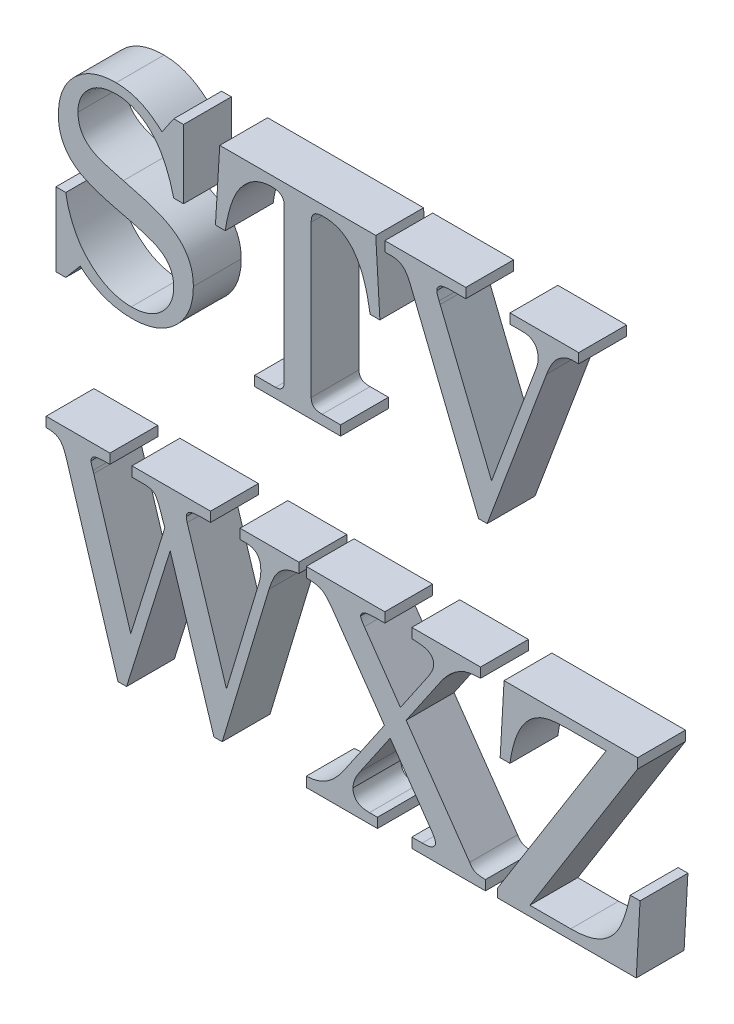
from build123d import *

# Parameters (mm, degrees)
BOSS_EXTRU_1_DEPTH   = 10
BOSS_EXTRU_1_2_DEPTH = 10
BOSS_EXTRU_1_3_DEPTH = 10
BOSS_EXTRU_1_4_DEPTH = 10
BOSS_EXTRU_1_5_DEPTH = 10
BOSS_EXTRU_1_6_DEPTH = 10


with BuildPart() as part:
    # Esquisse1 → Boss.-Extru.1 (new body)
    with BuildSketch(Plane.XY):
        with BuildLine():
            Line((25.240384615, 36.41025641), (27.692307692, 40))
            Line((27.692307692, 40), (29.743589744, 40))
            Line((29.743589744, 40), (29.743589744, 25.641025641))
            Line((29.743589744, 25.641025641), (27.692307692, 25.641025641))
            add(Edge.make_bspline(
                [(27.692307692, 25.641025641), (27.553181711, 26.179311808), (27.282139165, 27.227990507), (26.802654808, 28.731888364), (26.274272502, 30.123518089), (25.698788399, 31.40146317), (25.073905469, 32.567144603), (24.402423476, 33.624942096), (23.671265147, 34.562887028), (22.899710677, 35.395222104), (22.085774967, 36.11732818), (21.245314447, 36.749090998), (20.364784693, 37.267931511), (19.464598535, 37.707675003), (18.529639623, 38.045427942), (17.563164047, 38.285607061), (16.567118961, 38.434319164), (15.892603331, 38.452421333), (15.552884615, 38.461538462)],
                knots=[0, 0, 0, 0, 0.001667687, 0.003248956, 0.004732627, 0.006131202, 0.007450498, 0.008697438, 0.009885121, 0.011013336, 0.01209732, 0.013145408, 0.014162311, 0.015158611, 0.016147147, 0.017138278, 0.018142282, 0.019161045, 0.019161045, 0.019161045, 0.019161045], degree=3))
            add(Edge.make_bspline(
                [(15.552884615, 38.461538462), (15.272209756, 38.455302295), (14.719850589, 38.443029718), (13.911469306, 38.348994358), (13.142779475, 38.176929329), (12.412137501, 37.946451231), (11.719817849, 37.648188369), (11.064576365, 37.287268778), (10.455177464, 36.850531061), (9.888602709, 36.357009981), (9.380562766, 35.813737068), (8.927185364, 35.242214959), (8.539763693, 34.64394813), (8.234084963, 34.009426851), (7.992344887, 33.349151471), (7.816038992, 32.659722843), (7.70807936, 31.939857185), (7.69762473, 31.450699764), (7.692307692, 31.201923077)],
                knots=[0, 0, 0, 0, 0.000841956, 0.001656943, 0.002436538, 0.003201835, 0.003952008, 0.004694482, 0.005441524, 0.006196815, 0.00694506, 0.007669633, 0.008383134, 0.009078359, 0.009778002, 0.010489295, 0.011210004, 0.011955885, 0.011955885, 0.011955885, 0.011955885], degree=3))
            add(Edge.make_bspline(
                [(7.692307692, 31.201923077), (7.699248617, 30.893880321), (7.712750542, 30.29465611), (7.8845465, 29.426813587), (8.134269771, 28.612629636), (8.499872163, 27.859599457), (8.966724295, 27.171098619), (9.548415028, 26.556699063), (10.223004408, 26.003472237), (10.870971957, 25.596855719), (11.473790534, 25.304838429), (12.021905423, 25.072016406), (12.662222215, 24.835627315), (13.390172204, 24.585013966), (14.211354752, 24.343156674), (15.116187379, 24.072217211), (16.117575475, 23.81324236), (16.816095668, 23.639872024), (17.179487179, 23.549679487)],
                knots=[0, 0, 0, 0, 0.000922728, 0.001794948, 0.002643891, 0.003471736, 0.004296278, 0.00512965, 0.006000692, 0.006907806, 0.007416667, 0.00800902, 0.008693636, 0.009463951, 0.010318172, 0.011261441, 0.012297359, 0.013420641, 0.013420641, 0.013420641, 0.013420641], degree=3))
            add(Edge.make_bspline(
                [(17.179487179, 23.549679487), (17.692722554, 23.420396835), (18.680961183, 23.171462102), (20.105112481, 22.785378511), (21.41578255, 22.405792592), (22.61318463, 22.016892989), (23.699593848, 21.645045209), (24.673814989, 21.277244957), (25.533718177, 20.911471476), (26.511256747, 20.426104367), (27.595160321, 19.797243684), (28.722158388, 18.92220408), (29.680096621, 17.957028879), (30.458532703, 16.889605146), (31.056086728, 15.725167458), (31.496480116, 14.47373712), (31.742780636, 13.118573256), (31.777196472, 12.185790418), (31.794871795, 11.706730769)],
                knots=[0, 0, 0, 0, 0.001587772, 0.003057268, 0.004426499, 0.005680832, 0.006833815, 0.007871065, 0.00880431, 0.009635676, 0.011144556, 0.012555017, 0.013903554, 0.015211388, 0.016501551, 0.017816753, 0.019177753, 0.020614754, 0.020614754, 0.020614754, 0.020614754], degree=3))
            add(Edge.make_bspline(
                [(31.794871795, 11.706730769), (31.784598641, 11.276112882), (31.764417411, 10.430180018), (31.590533483, 9.190667589), (31.314921376, 8.004266225), (30.907158911, 6.880011916), (30.404749065, 5.803277343), (29.771791632, 4.793886611), (29.039992356, 3.830741723), (28.194344492, 2.941307065), (27.259659656, 2.134242835), (26.253213253, 1.425494413), (25.183772831, 0.820797931), (24.045313265, 0.328008179), (22.83772445, -0.04505345), (21.56731616, -0.318967924), (20.231163121, -0.479940307), (19.319345284, -0.501712882), (18.854166667, -0.512820513)],
                knots=[0, 0, 0, 0, 0.001291283, 0.002536677, 0.003747488, 0.00493868, 0.006117899, 0.007305312, 0.008505685, 0.009741323, 0.010979816, 0.012204729, 0.013428201, 0.014659206, 0.015918749, 0.017213755, 0.018553503, 0.019948861, 0.019948861, 0.019948861, 0.019948861], degree=3))
            add(Edge.make_bspline(
                [(18.854166667, -0.512820513), (18.348699871, -0.501037152), (17.352712679, -0.477818859), (15.883263236, -0.277315957), (14.465374422, 0.037644294), (13.098626932, 0.493907672), (11.781796541, 1.068874362), (10.518356381, 1.781907837), (9.299626653, 2.61450555), (8.546539029, 3.261838478), (8.165064103, 3.58974359)],
                knots=[0, 0, 0, 0, 0.001515779, 0.002986737, 0.004440772, 0.005867346, 0.007302514, 0.008744666, 0.010213812, 0.011721947, 0.011721947, 0.011721947, 0.011721947], degree=3))
            Line((8.165064103, 3.58974359), (5.128205128, 0))
            Line((5.128205128, 0), (3.076923077, 0))
            Line((3.076923077, 0), (3.076923077, 15.384615385))
            Line((3.076923077, 15.384615385), (5.128205128, 15.384615385))
            add(Edge.make_bspline(
                [(5.128205128, 15.384615385), (5.227295246, 14.862009498), (5.421431873, 13.838123903), (5.838745888, 12.360227949), (6.321047277, 10.957720396), (6.908874894, 9.644591262), (7.574068258, 8.413905481), (8.321983933, 7.265211629), (9.165094836, 6.208715581), (10.085892136, 5.239375239), (11.064054699, 4.373756667), (12.076720867, 3.612806258), (13.126060144, 2.973725784), (14.207153902, 2.456645172), (15.314350023, 2.036576413), (16.457884168, 1.753826597), (17.630125488, 1.567988769), (18.423434687, 1.548337408), (18.822115385, 1.538461538)],
                knots=[0, 0, 0, 0, 0.001595034, 0.00312498, 0.004602406, 0.006040813, 0.00743555, 0.008795678, 0.010147187, 0.011484776, 0.01280166, 0.01406128, 0.015280203, 0.01648079, 0.017652143, 0.01882596, 0.020009038, 0.021204265, 0.021204265, 0.021204265, 0.021204265], degree=3))
            add(Edge.make_bspline(
                [(18.822115385, 1.538461538), (19.140180676, 1.547428591), (19.764651593, 1.56503398), (20.680196455, 1.665651369), (21.551164166, 1.852853228), (22.377850006, 2.108275627), (23.162468253, 2.435154228), (23.891585787, 2.851804309), (24.588812069, 3.321558529), (25.221703547, 3.87438076), (25.797035009, 4.473290096), (26.306268941, 5.105907902), (26.732101466, 5.776896733), (27.088626844, 6.475411869), (27.36227179, 7.209466495), (27.553823886, 7.972710364), (27.668600027, 8.767889318), (27.684298307, 9.307844148), (27.692307692, 9.583333333)],
                knots=[0, 0, 0, 0, 0.000954367, 0.001873749, 0.00275854, 0.003622774, 0.004466596, 0.005302468, 0.006138148, 0.006984668, 0.007817731, 0.008627383, 0.009416473, 0.010197672, 0.010976071, 0.011761205, 0.012554433, 0.013380726, 0.013380726, 0.013380726, 0.013380726], degree=3))
            add(Edge.make_bspline(
                [(27.692307692, 9.583333333), (27.68194472, 9.891254008), (27.661685608, 10.49322411), (27.49074658, 11.368858625), (27.201004896, 12.184165029), (26.794266985, 12.941590037), (26.267227117, 13.638486949), (25.606548465, 14.273334742), (24.802340866, 14.828846703), (24.031904302, 15.248770641), (23.308867989, 15.57392759), (22.633586054, 15.827349554), (21.840217895, 16.087229272), (20.929938511, 16.369952622), (19.901494168, 16.664212569), (18.749234303, 16.967842177), (17.481080511, 17.288370641), (16.592228885, 17.496097613), (16.129807692, 17.604166667)],
                knots=[0, 0, 0, 0, 0.00092318, 0.001804772, 0.002663939, 0.003510004, 0.004373792, 0.005274833, 0.006246369, 0.007297057, 0.007903178, 0.008623441, 0.009459621, 0.010407507, 0.011482838, 0.012668438, 0.013982174, 0.01540679, 0.01540679, 0.01540679, 0.01540679], degree=3))
            add(Edge.make_bspline(
                [(16.129807692, 17.604166667), (15.618979592, 17.729742315), (14.63427351, 17.971810252), (13.219982688, 18.364599653), (11.922260737, 18.769265224), (10.744720407, 19.195056025), (9.68214472, 19.622654224), (8.744927093, 20.072956892), (7.916701023, 20.523762058), (7.427939651, 20.863893873), (7.195512821, 21.025641026)],
                knots=[0, 0, 0, 0, 0.001578037, 0.00304193, 0.004402812, 0.005654916, 0.006797692, 0.007837045, 0.008773311, 0.009622254, 0.009622254, 0.009622254, 0.009622254], degree=3))
            add(Edge.make_bspline(
                [(7.195512821, 21.025641026), (6.909215095, 21.256868185), (6.343332173, 21.713901159), (5.606504506, 22.503659275), (4.977502328, 23.362434111), (4.476885052, 24.299291492), (4.067445086, 25.298268336), (3.792418677, 26.37421358), (3.619471551, 27.518399719), (3.599822213, 28.305971302), (3.58974359, 28.709935897)],
                knots=[0, 0, 0, 0, 0.00110292, 0.002179982, 0.003229784, 0.004287506, 0.00535883, 0.006460818, 0.007611014, 0.008822249, 0.008822249, 0.008822249, 0.008822249], degree=3))
            add(Edge.make_bspline(
                [(3.58974359, 28.709935897), (3.601614972, 29.132352706), (3.624910044, 29.961256205), (3.775347577, 31.17519074), (4.041353115, 32.332450589), (4.417712401, 33.426838537), (4.895029112, 34.467617259), (5.480555315, 35.445776707), (6.176587276, 36.364330471), (6.966803201, 37.219551246), (7.843172501, 37.991386634), (8.784810291, 38.668669299), (9.78536255, 39.243050089), (10.84738629, 39.707079383), (11.969076894, 40.071377248), (13.151125384, 40.321120884), (14.388771201, 40.491169831), (15.234449304, 40.505515682), (15.665064103, 40.512820513)],
                knots=[0, 0, 0, 0, 0.001267268, 0.002486744, 0.003662692, 0.004823252, 0.005952605, 0.007091807, 0.008236042, 0.009404101, 0.010579257, 0.011733354, 0.01287829, 0.014033582, 0.015204277, 0.016409747, 0.017654084, 0.018945044, 0.018945044, 0.018945044, 0.018945044], degree=3))
            add(Edge.make_bspline(
                [(15.665064103, 40.512820513), (16.085049285, 40.502985724), (16.915473481, 40.483539688), (18.144832223, 40.299195909), (19.342159024, 40.003668978), (20.51945144, 39.582136122), (21.687366395, 39.016847232), (22.87081849, 38.308824432), (24.06451382, 37.427656182), (24.838930687, 36.757606762), (25.240384615, 36.41025641)],
                knots=[0, 0, 0, 0, 0.001259263, 0.002489902, 0.003720073, 0.004954385, 0.006233855, 0.007606669, 0.00908594, 0.010678215, 0.010678215, 0.010678215, 0.010678215], degree=3))
        make_face()
    extrude(amount=BOSS_EXTRU_1_DEPTH)


with BuildPart() as body_2:
    # Esquisse1 → Boss.-Extru.1 2 (new body)
    with BuildSketch(Plane.XY):
        with BuildLine():
            Line((37.307692308, 40), (69.903846154, 40))
            Line((69.903846154, 40), (70.769230769, 25.128205128))
            Line((70.769230769, 25.128205128), (68.717948718, 25.128205128))
            add(Edge.make_bspline(
                [(68.717948718, 25.128205128), (68.636550102, 25.64708069), (68.478670366, 26.653485231), (68.181635563, 28.108354031), (67.841608832, 29.463035931), (67.445099767, 30.715466879), (67.021305448, 31.875062607), (66.526317264, 32.925477474), (66.00398304, 33.885549653), (65.421452018, 34.736779972), (64.808044379, 35.501675558), (64.128262052, 36.149579207), (63.414298556, 36.712250919), (62.644110542, 37.162224119), (61.830767468, 37.520714641), (60.967278617, 37.764192916), (60.0620966, 37.925141897), (59.442490838, 37.940757023), (59.126602564, 37.948717949)],
                knots=[0, 0, 0, 0, 0.001575492, 0.003055806, 0.004453118, 0.005763331, 0.006995639, 0.00815354, 0.009243902, 0.010270669, 0.011244318, 0.012179349, 0.013081708, 0.013965337, 0.014848094, 0.015740724, 0.016650981, 0.017597716, 0.017597716, 0.017597716, 0.017597716], degree=3))
            add(Edge.make_bspline(
                [(59.126602564, 37.948717949), (58.88846848, 37.944303443), (58.44687272, 37.936117185), (57.84386134, 37.835634707), (57.35710928, 37.672425736), (56.975480164, 37.435827793), (56.71811376, 37.094671977), (56.531855697, 36.688271899), (56.432997427, 36.190320088), (56.418233977, 35.833718576), (56.41025641, 35.641025641)],
                knots=[0, 0, 0, 0, 0.000713861, 0.001323783, 0.001825593, 0.002247847, 0.002647043, 0.003088039, 0.003579964, 0.004158276, 0.004158276, 0.004158276, 0.004158276], degree=3))
            Line((56.41025641, 35.641025641), (56.41025641, 3.926282051))
            add(Edge.make_bspline(
                [(56.41025641, 3.926282051), (56.414572578, 3.775875613), (56.422711861, 3.492244282), (56.531881444, 3.097969622), (56.696129476, 2.761476266), (56.943092041, 2.489784073), (57.271798787, 2.284295305), (57.682959722, 2.146309791), (58.178303859, 2.069868353), (58.533363542, 2.057818405), (58.725961538, 2.051282051)],
                knots=[0, 0, 0, 0, 0.000449861, 0.000848333, 0.001217445, 0.001563484, 0.001934677, 0.002368037, 0.002855437, 0.00343325, 0.00343325, 0.00343325, 0.00343325], degree=3))
            Line((58.725961538, 2.051282051), (62.564102564, 2.051282051))
            Line((62.564102564, 2.051282051), (62.564102564, 0))
            Line((62.564102564, 0), (44.615384615, 0))
            Line((44.615384615, 0), (44.615384615, 2.051282051))
            Line((44.615384615, 2.051282051), (48.974358974, 2.051282051))
            add(Edge.make_bspline(
                [(48.974358974, 2.051282051), (49.11082903, 2.058461363), (49.370273561, 2.072110021), (49.737972734, 2.14608526), (50.050730768, 2.295773456), (50.313029207, 2.496832162), (50.510622604, 2.752282351), (50.673939749, 3.034115284), (50.747793654, 3.367283856), (50.761870758, 3.597554853), (50.769230769, 3.717948718)],
                knots=[0, 0, 0, 0, 0.000409909, 0.000779282, 0.001116201, 0.001441585, 0.001760693, 0.0020798, 0.002410177, 0.002772176, 0.002772176, 0.002772176, 0.002772176], degree=3))
            Line((50.769230769, 3.717948718), (50.769230769, 35.881410256))
            add(Edge.make_bspline(
                [(50.769230769, 35.881410256), (50.761513761, 36.042220834), (50.746894452, 36.346864766), (50.638159293, 36.778060346), (50.43094411, 37.138487561), (50.147185925, 37.440348655), (49.775428711, 37.674146957), (49.312640697, 37.843861647), (48.756015685, 37.93235937), (48.354983293, 37.94302673), (48.141025641, 37.948717949)],
                knots=[0, 0, 0, 0, 0.000482436, 0.000913939, 0.001319439, 0.001716215, 0.002145182, 0.002624412, 0.003185596, 0.003827422, 0.003827422, 0.003827422, 0.003827422], degree=3))
            add(Edge.make_bspline(
                [(48.141025641, 37.948717949), (47.81977755, 37.938245835), (47.186106912, 37.917589304), (46.256697078, 37.744137729), (45.370474947, 37.460347878), (44.517764545, 37.075997649), (43.717112964, 36.561983868), (42.946805191, 35.951954917), (42.233835267, 35.213323915), (41.800840602, 34.664697342), (41.578525641, 34.383012821)],
                knots=[0, 0, 0, 0, 0.000963173, 0.001899885, 0.002824837, 0.003749927, 0.004696967, 0.005671801, 0.00669173, 0.007767986, 0.007767986, 0.007767986, 0.007767986], degree=3))
            add(Edge.make_bspline(
                [(41.578525641, 34.383012821), (41.400397257, 34.124106189), (41.030416578, 33.586345453), (40.544210115, 32.689543917), (40.098284908, 31.686342522), (39.691349144, 30.577469885), (39.323739493, 29.36522144), (39.000110092, 28.047939745), (38.698940288, 26.627260349), (38.542460274, 25.639179569), (38.461538462, 25.128205128)],
                knots=[0, 0, 0, 0, 0.000942282, 0.001957162, 0.003054684, 0.00423355, 0.005498383, 0.006852929, 0.008301854, 0.009853634, 0.009853634, 0.009853634, 0.009853634], degree=3))
            Line((38.461538462, 25.128205128), (36.41025641, 25.128205128))
            Line((36.41025641, 25.128205128), (37.307692308, 40))
        make_face()
    extrude(amount=BOSS_EXTRU_1_2_DEPTH)


with BuildPart() as body_3:
    # Esquisse1 → Boss.-Extru.1 3 (new body)
    with BuildSketch(Plane.XY):
        with BuildLine():
            Line((71.794871795, 40), (88.717948718, 40))
            Line((88.717948718, 40), (88.717948718, 37.948717949))
            Line((88.717948718, 37.948717949), (85.78525641, 37.948717949))
            add(Edge.make_bspline(
                [(85.78525641, 37.948717949), (85.507305431, 37.945423797), (84.995404143, 37.93935697), (84.29865745, 37.865492139), (83.744132865, 37.735460744), (83.322946631, 37.553985279), (83.025899664, 37.313444598), (82.807281085, 37.047276114), (82.68239482, 36.72993179), (82.667720776, 36.507418445), (82.66025641, 36.394230769)],
                knots=[0, 0, 0, 0, 0.00083368, 0.001535385, 0.002097026, 0.002538023, 0.002897172, 0.003233806, 0.003561157, 0.003900072, 0.003900072, 0.003900072, 0.003900072], degree=3))
            add(Edge.make_bspline(
                [(82.66025641, 36.394230769), (82.668482307, 36.292374838), (82.687099859, 36.06184578), (82.780814489, 35.687918514), (82.936724647, 35.252145916), (83.074451332, 34.94823795), (83.149038462, 34.783653846)],
                knots=[0, 0, 0, 0, 0.000306169, 0.000692949, 0.001151643, 0.001693502, 0.001693502, 0.001693502, 0.001693502], degree=3))
            Line((83.149038462, 34.783653846), (83.365384615, 34.22275641))
            Line((83.365384615, 34.22275641), (94.102564103, 7.692307692))
            Line((94.102564103, 7.692307692), (103.549679487, 33.012820513))
            add(Edge.make_bspline(
                [(103.549679487, 33.012820513), (103.627655526, 33.286213658), (103.79557832, 33.874970686), (103.807641174, 34.487570182), (103.814102564, 34.815705128)],
                knots=[0, 0, 0, 0, 0.000849283, 0.001828947, 0.001828947, 0.001828947, 0.001828947], degree=3))
            add(Edge.make_bspline(
                [(103.814102564, 34.815705128), (103.804173661, 35.051873738), (103.785296953, 35.500874572), (103.620639846, 36.132040398), (103.357808379, 36.68554533), (102.969312774, 37.137907898), (102.500336337, 37.506783594), (101.937281807, 37.763348708), (101.296838005, 37.929149342), (100.839801295, 37.942001582), (100.600961538, 37.948717949)],
                knots=[0, 0, 0, 0, 0.000707356, 0.001344816, 0.001943261, 0.002529075, 0.003117294, 0.003719483, 0.004372466, 0.005087226, 0.005087226, 0.005087226, 0.005087226], degree=3))
            Line((100.600961538, 37.948717949), (97.948717949, 37.948717949))
            Line((97.948717949, 37.948717949), (97.948717949, 40))
            Line((97.948717949, 40), (112.307692308, 40))
            Line((112.307692308, 40), (112.307692308, 37.948717949))
            Line((112.307692308, 37.948717949), (111.025641026, 37.948717949))
            add(Edge.make_bspline(
                [(111.025641026, 37.948717949), (110.78402759, 37.933317738), (110.289601288, 37.901803476), (109.550213208, 37.685641233), (108.825991446, 37.309840693), (108.089613709, 36.812472889), (107.381152298, 36.112684042), (106.725502423, 35.189494328), (106.122181755, 34.038720592), (105.777197165, 33.181943951), (105.592948718, 32.724358974)],
                knots=[0, 0, 0, 0, 0.000724751, 0.001483095, 0.00228937, 0.00316508, 0.004139684, 0.005258413, 0.006548949, 0.008028265, 0.008028265, 0.008028265, 0.008028265], degree=3))
            Line((105.592948718, 32.724358974), (93.189102564, -0.512820513))
            Line((93.189102564, -0.512820513), (91.386217949, -0.512820513))
            Line((91.386217949, -0.512820513), (77.131410256, 34.743589744))
            add(Edge.make_bspline(
                [(77.131410256, 34.743589744), (77.017401258, 35.024256058), (76.802933622, 35.552230534), (76.408237963, 36.252974889), (75.99687582, 36.82430275), (75.540597741, 37.263970295), (75.020353021, 37.581173943), (74.42524474, 37.791051666), (73.754005129, 37.933587088), (73.278068479, 37.943517781), (73.028846154, 37.948717949)],
                knots=[0, 0, 0, 0, 0.000907998, 0.001708077, 0.002406802, 0.003013294, 0.003595975, 0.004219639, 0.004898509, 0.005644778, 0.005644778, 0.005644778, 0.005644778], degree=3))
            Line((73.028846154, 37.948717949), (71.794871795, 37.948717949))
            Line((71.794871795, 37.948717949), (71.794871795, 40))
        make_face()
    extrude(amount=BOSS_EXTRU_1_3_DEPTH)


with BuildPart() as body_4:
    # Esquisse1 → Boss.-Extru.1 4 (new body)
    with BuildSketch(Plane.XY):
        with BuildLine():
            Line((1.025641026, -27.153846154), (14.358974359, -27.153846154))
            Line((14.358974359, -27.153846154), (14.358974359, -29.205128205))
            Line((14.358974359, -29.205128205), (13.485576923, -29.205128205))
            add(Edge.make_bspline(
                [(13.485576923, -29.205128205), (13.188841123, -29.205387587), (12.653261539, -29.205855745), (11.939173578, -29.273027287), (11.390963754, -29.35291882), (10.995802068, -29.497401091), (10.724721967, -29.692202919), (10.547490017, -29.934613436), (10.428772395, -30.217715273), (10.420787447, -30.427165648), (10.416666667, -30.53525641)],
                knots=[0, 0, 0, 0, 0.000889567, 0.001605584, 0.002150985, 0.00254679, 0.002856089, 0.003136537, 0.00343859, 0.003760701, 0.003760701, 0.003760701, 0.003760701], degree=3))
            add(Edge.make_bspline(
                [(10.416666667, -30.53525641), (10.422010779, -30.626466743), (10.434267126, -30.835651263), (10.526420518, -31.179568321), (10.651883522, -31.594619065), (10.764494025, -31.890084196), (10.825320513, -32.049679487)],
                knots=[0, 0, 0, 0, 0.000273494, 0.00062724, 0.001063185, 0.001575254, 0.001575254, 0.001575254, 0.001575254], degree=3))
            Line((10.825320513, -32.049679487), (10.985576923, -32.554487179))
            Line((10.985576923, -32.554487179), (18.717948718, -57.666666667))
            Line((18.717948718, -57.666666667), (25.833333333, -34.958333333))
            add(Edge.make_bspline(
                [(25.833333333, -34.958333333), (25.721613704, -34.618979779), (25.509264338, -33.973958729), (25.20188445, -33.063899911), (24.908332679, -32.270744782), (24.658464525, -31.58106834), (24.410254472, -31.012107879), (24.192925691, -30.548913413), (24.008837402, -30.195592705), (23.779725455, -29.867452408), (23.408925148, -29.572450631), (22.833839631, -29.36023131), (22.116107639, -29.227248761), (21.58727658, -29.212948519), (21.298076923, -29.205128205)],
                knots=[0, 0, 0, 0, 0.001071833, 0.002037269, 0.002881358, 0.003609115, 0.00423724, 0.00474262, 0.005144221, 0.005431121, 0.005937959, 0.006534632, 0.007252797, 0.008119516, 0.008119516, 0.008119516, 0.008119516], degree=3))
            Line((21.298076923, -29.205128205), (18.974358974, -29.205128205))
            Line((18.974358974, -29.205128205), (18.974358974, -27.153846154))
            Line((18.974358974, -27.153846154), (35.384615385, -27.153846154))
            Line((35.384615385, -27.153846154), (35.384615385, -29.205128205))
            Line((35.384615385, -29.205128205), (33.758012821, -29.205128205))
            add(Edge.make_bspline(
                [(33.758012821, -29.205128205), (33.43472174, -29.209597381), (32.848801328, -29.217697144), (32.060520544, -29.275677965), (31.452320607, -29.376058891), (31.007124856, -29.533383797), (30.703824824, -29.748831773), (30.491136019, -29.99721994), (30.364469242, -30.300101465), (30.351367691, -30.518028351), (30.344551282, -30.631410256)],
                knots=[0, 0, 0, 0, 0.000969849, 0.001757718, 0.00236906, 0.002815482, 0.003160127, 0.003473037, 0.003785537, 0.004124452, 0.004124452, 0.004124452, 0.004124452], degree=3))
            add(Edge.make_bspline(
                [(30.344551282, -30.631410256), (30.350508092, -30.811526254), (30.362120476, -31.162649828), (30.458074999, -31.500514166), (30.504807692, -31.665064103)],
                knots=[0, 0, 0, 0, 0.000538352, 0.001049479, 0.001049479, 0.001049479, 0.001049479], degree=3))
            Line((30.504807692, -31.665064103), (38.717948718, -57.666666667))
            Line((38.717948718, -57.666666667), (45.488782051, -35.174679487))
            add(Edge.make_bspline(
                [(45.488782051, -35.174679487), (45.606906031, -34.749994978), (45.835325077, -33.928772811), (45.877210826, -33.077644763), (45.897435897, -32.666666667)],
                knots=[0, 0, 0, 0, 0.001317713, 0.002548092, 0.002548092, 0.002548092, 0.002548092], degree=3))
            add(Edge.make_bspline(
                [(45.897435897, -32.666666667), (45.890443556, -32.388023956), (45.877342703, -31.86595892), (45.724620754, -31.142144492), (45.479056808, -30.528892367), (45.118279623, -30.0322791), (44.65430724, -29.656088133), (44.097625979, -29.381370097), (43.439149259, -29.238386777), (42.970691792, -29.216589857), (42.724358974, -29.205128205)],
                knots=[0, 0, 0, 0, 0.000834719, 0.00156393, 0.002206806, 0.002802994, 0.003383689, 0.003982134, 0.004648789, 0.005388099, 0.005388099, 0.005388099, 0.005388099], degree=3))
            Line((42.724358974, -29.205128205), (41.538461538, -29.205128205))
            Line((41.538461538, -29.205128205), (41.538461538, -27.153846154))
            Line((41.538461538, -27.153846154), (53.846153846, -27.153846154))
            Line((53.846153846, -27.153846154), (53.846153846, -29.205128205))
            add(Edge.make_bspline(
                [(53.846153846, -29.205128205), (53.562241474, -29.243136467), (53.022650451, -29.315373253), (52.26335282, -29.49190996), (51.595488679, -29.71539956), (51.007192062, -29.979806871), (50.487081583, -30.303439603), (50.011506464, -30.682950612), (49.569410551, -31.127528341), (49.148282971, -31.647398544), (48.739696798, -32.28700024), (48.372396457, -33.098895103), (47.961141281, -34.067846742), (47.728951321, -34.787773147), (47.604166667, -35.174679487)],
                knots=[0, 0, 0, 0, 0.00085898, 0.001632539, 0.002334428, 0.002969061, 0.003562767, 0.004167191, 0.004790442, 0.005439926, 0.006171247, 0.007060056, 0.008109123, 0.009327942, 0.009327942, 0.009327942, 0.009327942], degree=3))
            Line((47.604166667, -35.174679487), (37.820512821, -67.666666667))
            Line((37.820512821, -67.666666667), (36.08974359, -67.666666667))
            Line((36.08974359, -67.666666667), (26.955128205, -38.548076923))
            Line((26.955128205, -38.548076923), (17.836538462, -67.666666667))
            Line((17.836538462, -67.666666667), (16.041666667, -67.666666667))
            Line((16.041666667, -67.666666667), (5.232371795, -32.554487179))
            add(Edge.make_bspline(
                [(5.232371795, -32.554487179), (5.123813093, -32.239554357), (4.923330337, -31.657946441), (4.557316679, -30.888605699), (4.16963292, -30.291497774), (3.738759883, -29.845084559), (3.220184618, -29.542667668), (2.599042435, -29.338458348), (1.852435871, -29.224352251), (1.314510291, -29.211844788), (1.025641026, -29.205128205)],
                knots=[0, 0, 0, 0, 0.00099881, 0.001844571, 0.002549061, 0.003126985, 0.003687654, 0.004331278, 0.005078192, 0.005944503, 0.005944503, 0.005944503, 0.005944503], degree=3))
            Line((1.025641026, -29.205128205), (1.025641026, -27.153846154))
        make_face()
    extrude(amount=BOSS_EXTRU_1_4_DEPTH)


with BuildPart() as body_5:
    # Esquisse1 → Boss.-Extru.1 5 (new body)
    with BuildSketch(Plane.XY):
        with BuildLine():
            Line((55.384615385, -27.153846154), (71.794871795, -27.153846154))
            Line((71.794871795, -27.153846154), (71.794871795, -29.205128205))
            Line((71.794871795, -29.205128205), (70.008012821, -29.205128205))
            add(Edge.make_bspline(
                [(70.008012821, -29.205128205), (69.711449934, -29.209801381), (69.170910303, -29.21831909), (68.438293073, -29.275068205), (67.861651709, -29.381694297), (67.428057153, -29.528998655), (67.117686154, -29.723237172), (66.906482662, -29.941620676), (66.759555793, -30.183083498), (66.745654804, -30.359763477), (66.738782051, -30.447115385)],
                knots=[0, 0, 0, 0, 0.000889748, 0.001621727, 0.002201592, 0.002645201, 0.002987509, 0.003287856, 0.003553248, 0.00381277, 0.00381277, 0.00381277, 0.00381277], degree=3))
            add(Edge.make_bspline(
                [(66.738782051, -30.447115385), (66.750970091, -30.53109618), (66.780951808, -30.737683016), (66.959851512, -31.070057693), (67.192212948, -31.506876841), (67.405216305, -31.814161002), (67.524038462, -31.985576923)],
                knots=[0, 0, 0, 0, 0.000253007, 0.00062238, 0.001117362, 0.001741848, 0.001741848, 0.001741848, 0.001741848], degree=3))
            Line((67.524038462, -31.985576923), (75.064102564, -42.834935897))
            Line((75.064102564, -42.834935897), (80.881410256, -34.309294872))
            add(Edge.make_bspline(
                [(80.881410256, -34.309294872), (81.051804746, -34.036884528), (81.367358109, -33.532408121), (81.735284541, -32.796824717), (81.965196825, -32.137884407), (82.002285137, -31.719847166), (82.019230769, -31.528846154)],
                knots=[0, 0, 0, 0, 0.000963306, 0.001783946, 0.002465601, 0.003039064, 0.003039064, 0.003039064, 0.003039064], degree=3))
            add(Edge.make_bspline(
                [(82.019230769, -31.528846154), (82.006851456, -31.358891477), (81.98292501, -31.030407081), (81.795294137, -30.564407385), (81.477776308, -30.165913653), (81.031434093, -29.812679556), (80.410523889, -29.542734752), (79.600749164, -29.353185141), (78.588034683, -29.229617067), (77.842301681, -29.213766392), (77.435897436, -29.205128205)],
                knots=[0, 0, 0, 0, 0.000508861, 0.000983515, 0.001480375, 0.002022234, 0.002674774, 0.003492946, 0.004510669, 0.005729566, 0.005729566, 0.005729566, 0.005729566], degree=3))
            Line((77.435897436, -29.205128205), (77.435897436, -27.153846154))
            Line((77.435897436, -27.153846154), (91.794871795, -27.153846154))
            Line((91.794871795, -27.153846154), (91.794871795, -29.205128205))
            add(Edge.make_bspline(
                [(91.794871795, -29.205128205), (91.3802602, -29.212490442), (90.593307118, -29.226464326), (89.48129844, -29.379814618), (88.498068688, -29.623002705), (87.918922659, -29.888497536), (87.644230769, -30.014423077)],
                knots=[0, 0, 0, 0, 0.001242917, 0.002359118, 0.003362002, 0.004266847, 0.004266847, 0.004266847, 0.004266847], degree=3))
            add(Edge.make_bspline(
                [(87.644230769, -30.014423077), (87.301759061, -30.211229169), (86.59961737, -30.614724579), (85.633830039, -31.407856627), (84.704028241, -32.344138071), (84.143767552, -33.05330217), (83.854166667, -33.419871795)],
                knots=[0, 0, 0, 0, 0.001183214, 0.002425848, 0.003734687, 0.005135121, 0.005135121, 0.005135121, 0.005135121], degree=3))
            Line((83.854166667, -33.419871795), (76.258012821, -44.549679487))
            Line((76.258012821, -44.549679487), (89.52724359, -63.620192308))
            add(Edge.make_bspline(
                [(89.52724359, -63.620192308), (89.602100225, -63.742075405), (89.747496965, -63.978813339), (90.000938105, -64.294256739), (90.289228911, -64.545354248), (90.606262294, -64.761182954), (91.006470154, -64.918039898), (91.511162229, -65.00976073), (92.126698508, -65.083560213), (92.577162474, -65.095898626), (92.820512821, -65.102564103)],
                knots=[0, 0, 0, 0, 0.000428967, 0.000833197, 0.001207834, 0.001572307, 0.001978519, 0.002486117, 0.003107304, 0.003837175, 0.003837175, 0.003837175, 0.003837175], degree=3))
            Line((92.820512821, -65.102564103), (92.820512821, -67.153846154))
            Line((92.820512821, -67.153846154), (77.435897436, -67.153846154))
            Line((77.435897436, -67.153846154), (77.435897436, -65.102564103))
            Line((77.435897436, -65.102564103), (79.599358974, -65.102564103))
            add(Edge.make_bspline(
                [(79.599358974, -65.102564103), (79.842511407, -65.098347612), (80.290044107, -65.090586975), (80.902060032, -65.027073028), (81.390311662, -64.900709974), (81.769907976, -64.734420013), (82.041357749, -64.516630867), (82.245973537, -64.282121018), (82.362145188, -64.00894692), (82.379301552, -63.818784015), (82.387820513, -63.724358974)],
                knots=[0, 0, 0, 0, 0.000729563, 0.001342792, 0.001840362, 0.002238269, 0.002574903, 0.00287653, 0.003163765, 0.003447061, 0.003447061, 0.003447061, 0.003447061], degree=3))
            add(Edge.make_bspline(
                [(82.387820513, -63.724358974), (82.376413417, -63.608512348), (82.350213566, -63.342435489), (82.183212086, -62.921433761), (81.917385422, -62.437038384), (81.698584508, -62.098966123), (81.578525641, -61.913461538)],
                knots=[0, 0, 0, 0, 0.000347889, 0.000799033, 0.001343905, 0.002006406, 0.002006406, 0.002006406, 0.002006406], degree=3))
            Line((81.578525641, -61.913461538), (72.916666667, -49.461538462))
            Line((72.916666667, -49.461538462), (66.586538462, -58.724358974))
            add(Edge.make_bspline(
                [(66.586538462, -58.724358974), (66.369647731, -59.050710955), (65.960711706, -59.666030388), (65.511715044, -60.608741228), (65.208482675, -61.491652903), (65.170309729, -62.071655558), (65.15224359, -62.346153846)],
                knots=[0, 0, 0, 0, 0.001173817, 0.002213169, 0.003128071, 0.003950117, 0.003950117, 0.003950117, 0.003950117], degree=3))
            add(Edge.make_bspline(
                [(65.15224359, -62.346153846), (65.163237174, -62.555386507), (65.184142167, -62.953255601), (65.336030481, -63.517554167), (65.608894518, -64.001356885), (65.984712956, -64.415055426), (66.483484834, -64.730183734), (67.086199561, -64.952698621), (67.799619606, -65.075688366), (68.308813914, -65.093185843), (68.581730769, -65.102564103)],
                knots=[0, 0, 0, 0, 0.000627512, 0.001193253, 0.001734934, 0.002279334, 0.002852741, 0.003486717, 0.004195523, 0.005014244, 0.005014244, 0.005014244, 0.005014244], degree=3))
            Line((68.581730769, -65.102564103), (70.256410256, -65.102564103))
            Line((70.256410256, -65.102564103), (70.256410256, -67.153846154))
            Line((70.256410256, -67.153846154), (55.384615385, -67.153846154))
            Line((55.384615385, -67.153846154), (55.384615385, -65.102564103))
            add(Edge.make_bspline(
                [(55.384615385, -65.102564103), (55.773101331, -65.074816068), (56.532992902, -65.020539979), (57.639525912, -64.775859982), (58.679484116, -64.388631118), (59.669926284, -63.856449161), (60.621640834, -63.158853742), (61.548512687, -62.285125964), (62.469998482, -61.231994188), (63.035878562, -60.439179047), (63.333333333, -60.022435897)],
                knots=[0, 0, 0, 0, 0.001167262, 0.002283204, 0.003386095, 0.004486684, 0.005645472, 0.006915448, 0.008300901, 0.009836188, 0.009836188, 0.009836188, 0.009836188], degree=3))
            Line((63.333333333, -60.022435897), (71.72275641, -47.738782051))
            Line((71.72275641, -47.738782051), (60.873397436, -32.145833333))
            add(Edge.make_bspline(
                [(60.873397436, -32.145833333), (60.666825349, -31.859290291), (60.284154155, -31.328474296), (59.691262787, -30.642460398), (59.140787792, -30.115108185), (58.585546685, -29.737172969), (57.963401357, -29.497177749), (57.231604349, -29.337983616), (56.357561403, -29.22437978), (55.724254291, -29.211848603), (55.384615385, -29.205128205)],
                knots=[0, 0, 0, 0, 0.0010593, 0.001962334, 0.002716434, 0.00334092, 0.003962882, 0.004703407, 0.005583979, 0.006602396, 0.006602396, 0.006602396, 0.006602396], degree=3))
            Line((55.384615385, -29.205128205), (55.384615385, -27.153846154))
        make_face()
    extrude(amount=BOSS_EXTRU_1_5_DEPTH)


with BuildPart() as body_6:
    # Esquisse1 → Boss.-Extru.1 6 (new body)
    with BuildSketch(Plane.XY):
        with BuildLine():
            Line((96.71474359, -27.153846154), (124.615384615, -27.153846154))
            Line((124.615384615, -27.153846154), (124.615384615, -29.205128205))
            Line((124.615384615, -29.205128205), (102.115384615, -65.102564103))
            Line((102.115384615, -65.102564103), (110.641025641, -65.102564103))
            add(Edge.make_bspline(
                [(110.641025641, -65.102564103), (111.226728758, -65.09029726), (112.343774116, -65.066902099), (113.936813654, -64.848713394), (115.365843992, -64.496693954), (116.638995193, -63.986198711), (117.771078409, -63.327616227), (118.779864153, -62.523387492), (119.687176728, -61.589145444), (120.339663378, -60.682249719), (120.813564228, -59.858409643), (121.166102853, -59.13636793), (121.497117711, -58.313368655), (121.835403485, -57.400895843), (122.162575514, -56.387366906), (122.481737909, -55.278660841), (122.784408179, -54.069101103), (122.976901732, -53.230576539), (123.076923077, -52.794871795)],
                knots=[0, 0, 0, 0, 0.001756289, 0.003349571, 0.004812959, 0.006161043, 0.007450136, 0.008727823, 0.010019852, 0.011345362, 0.012066916, 0.01286964, 0.013753523, 0.014727006, 0.015788728, 0.01694771, 0.018187601, 0.019528714, 0.019528714, 0.019528714, 0.019528714], degree=3))
            Line((123.076923077, -52.794871795), (125.128205128, -52.794871795))
            Line((125.128205128, -52.794871795), (124.334935897, -67.153846154))
            Line((124.334935897, -67.153846154), (95.384615385, -67.153846154))
            Line((95.384615385, -67.153846154), (95.384615385, -65.318910256))
            Line((95.384615385, -65.318910256), (118.028846154, -29.205128205))
            Line((118.028846154, -29.205128205), (109.695512821, -29.205128205))
            add(Edge.make_bspline(
                [(109.695512821, -29.205128205), (109.158103723, -29.212143964), (108.144946957, -29.225370506), (106.719735419, -29.38001239), (105.475817671, -29.613244029), (104.740736222, -29.892585745), (104.399038462, -30.022435897)],
                knots=[0, 0, 0, 0, 0.001611294, 0.003037711, 0.004298044, 0.005392784, 0.005392784, 0.005392784, 0.005392784], degree=3))
            add(Edge.make_bspline(
                [(104.399038462, -30.022435897), (104.189086909, -30.120741996), (103.76872413, -30.317569426), (103.166080518, -30.67110713), (102.595092365, -31.081793723), (102.056099327, -31.548516917), (101.550164728, -32.074210649), (101.07081908, -32.649942464), (100.619511767, -33.278290398), (100.202421089, -33.961611696), (99.819914271, -34.702955936), (99.45600006, -35.497715985), (99.130303162, -36.355213992), (98.834848123, -37.2735583), (98.562145758, -38.24860488), (98.323591904, -39.28359651), (98.113054459, -40.376525331), (98.004415432, -41.127703522), (97.948717949, -41.512820513)],
                knots=[0, 0, 0, 0, 0.000695225, 0.001391972, 0.002092441, 0.002802514, 0.00352784, 0.004278826, 0.005048223, 0.005846656, 0.006678138, 0.007549512, 0.00846767, 0.00942804, 0.010442856, 0.011504094, 0.012613573, 0.013780807, 0.013780807, 0.013780807, 0.013780807], degree=3))
            Line((97.948717949, -41.512820513), (95.897435897, -41.512820513))
            Line((95.897435897, -41.512820513), (96.71474359, -27.153846154))
        make_face()
    extrude(amount=BOSS_EXTRU_1_6_DEPTH)


solid = Compound([part.part, body_2.part, body_3.part, body_4.part, body_5.part, body_6.part])
